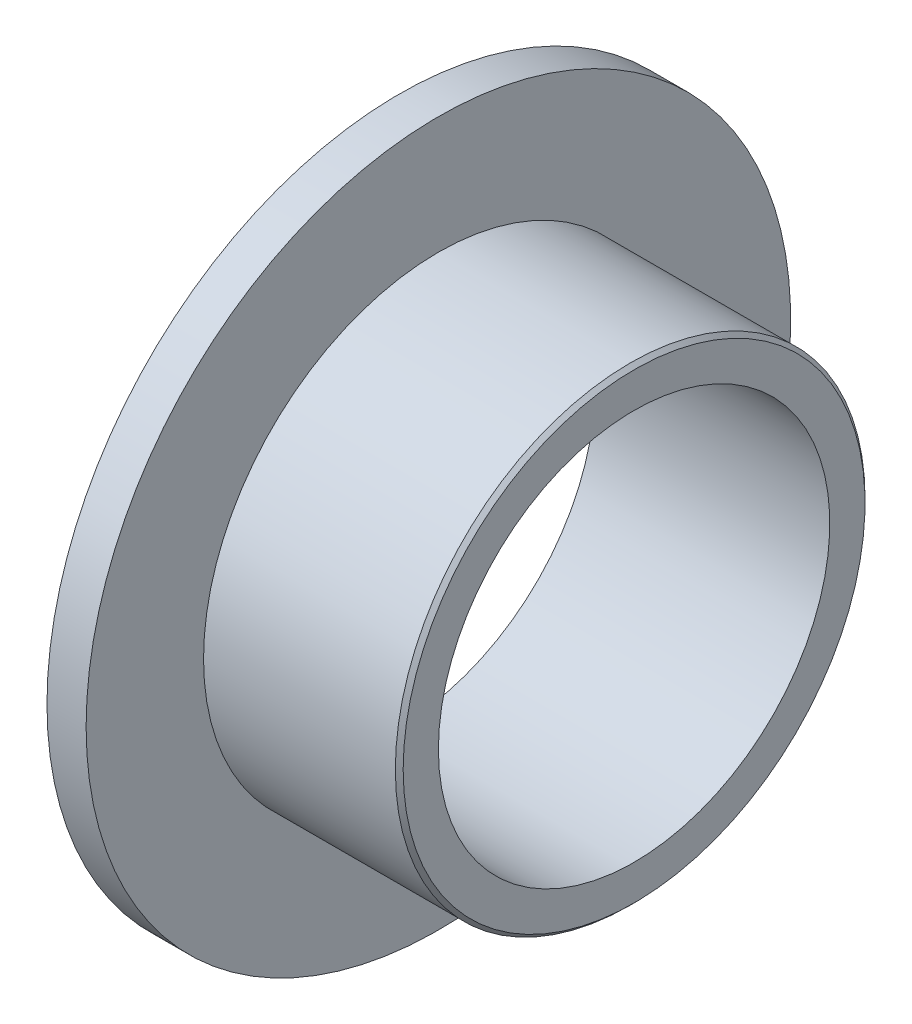
from build123d import *


with BuildPart() as part:
    # 草图1 → 旋转1 (revolve)
    with BuildSketch(Plane(origin=(0, 0, 0), x_dir=(-1, 0, 0), z_dir=(0, 0, -1))):
        Polygon((0, 9), (-1, 9), (-1, 6), (-5.9, 6), (-6, 5.9), (-6, 5), (0, 5), align=None)
    revolve(axis=Axis((4, 0, 0), (-1, 0, 0)))


solid = part.part
